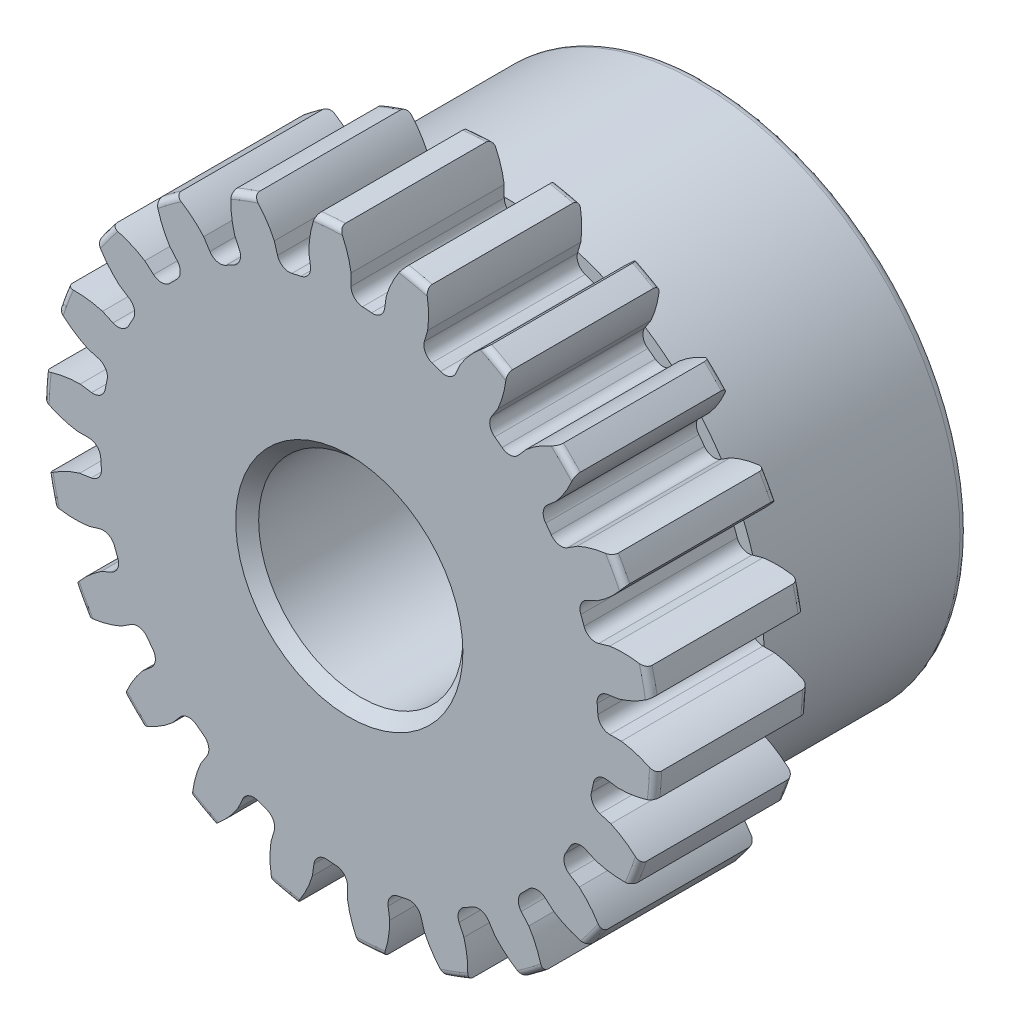
from build123d import *

# Parameters (mm, degrees)
SKETCH1_R                = 9.525
BOSS_EXTRUDE1_DEPTH      = 4.7625
SKETCH2_W                = 6.35
SKETCH2_H                = 7.14375
REVOLVE1_ANGLE           = 360
FILLET2_R                = 0.1905
CUT_EXTRUDE1_DEPTH       = 12.1125
FILLET1_R                = 0.374318784
CIRPATTERN1_COUNT        = 22
FILLET1_OF_CIRPATTERN1_R = 0.374318784
SKETCH5_R                = 3.175
CUT_EXTRUDE2_DEPTH       = 12.1125
CHAMFER1_SIZE            = 0.3571875
SKETCH6_R                = 8.128
BOSS_EXTRUDE2_DEPTH      = 6.35
FILLET3_R                = 0.254


with BuildPart() as part:
    # Sketch1 → Boss-Extrude1 (new body)
    with BuildSketch(Plane.XY):
        Circle(SKETCH1_R)
    extrude(amount=-BOSS_EXTRUDE1_DEPTH)

    # Sketch2 → Revolve1 (revolve, symmetric)
    with BuildSketch(Plane(origin=(0, 0, 0), x_dir=(0, 0, -1), z_dir=(1, 0, 0))) as revolve1_sk:
        with Locations((7.9375, 3.571875)):
            Rectangle(SKETCH2_W, SKETCH2_H)
    revolve(axis=Axis((0, 0, -4.7625), (0, 0, -1)), revolution_arc=REVOLVE1_ANGLE / 2)
    revolve(revolve1_sk.sketch, axis=Axis((0, 0, -4.7625), (0, 0, 1)), revolution_arc=REVOLVE1_ANGLE / 2)

    # Fillet2
    fillet2_edges = [part.edges().sort_by_distance(p)[0] for p in [
        (-9.525, 0, 0),
        (-9.525, 0, -4.7625),
    ]]
    fillet(fillet2_edges, radius=FILLET2_R)

    # Sketch4 → Cut-Extrude1 (cut, through all)
    with BuildSketch(Plane.XY):
        with BuildLine():
            Line((0.054821567, 8.459109181), (0.054821567, 7.73756943))
            ThreePointArc((0.054821567, 7.73756943), (0.552007026, 7.718048609), (1.04690994, 7.666613703))
            Line((1.04690994, 7.666613703), (1.149595991, 8.380809185))
            add(Edge.make_bspline(
                [(2.328590945, 10.036363463), (1.44460819, 9.360987761), (1.149595991, 8.380809185)],
                knots=[0, 0, 0, 1, 1, 1], degree=2))
            ThreePointArc((2.328590945, 10.036363463), (0.735006268, 10.276706337), (-0.876562375, 10.26560109))
            add(Edge.make_bspline(
                [(-0.876562375, 10.26560109), (-0.097693539, 9.471295617), (0.054821567, 8.459109181)],
                knots=[0, 0, 0, 1, 1, 1], degree=2))
        make_face()
    cut_extrude1 = extrude(amount=-CUT_EXTRUDE1_DEPTH, mode=Mode.SUBTRACT)

    # Fillet1
    fillet1_edges = [part.edges().sort_by_distance(p)[0] for p in [
        (1.04690994, 7.666613703, -2.38125),
        (0.054821567, 7.73756943, -2.38125),
    ]]
    fillet(fillet1_edges, radius=FILLET1_R)

    # CirPattern1: Cut-Extrude1 ×22 about axis
    cirpattern1_axis = Axis((0, 0, -4.7625), (0, 0, 1))
    for i in range(1, CIRPATTERN1_COUNT):
        add(cut_extrude1.rotate(cirpattern1_axis, i * 360 / CIRPATTERN1_COUNT), mode=Mode.SUBTRACT)

    # Fillet1 of CirPattern1
    fillet1_of_cirpattern1_edges = [part.edges().sort_by_distance(p)[0] for p in [
        (-1.15543195, 7.651010593, -2.38125),
        (-2.127324311, 7.439588521, -2.38125),
        (-3.264167614, 7.015568108, -2.38125),
        (-4.137127025, 6.538896396, -2.38125),
        (-5.108459831, 5.811766018, -2.38125),
        (-5.811764312, 5.108461772, -2.38125),
        (-6.538895014, 4.137129208, -2.38125),
        (-7.015567018, 3.264169957, -2.38125),
        (-7.439587811, 2.127326795, -2.38125),
        (-7.651010208, 1.155434505, -2.38125),
        (-7.737569449, -0.054818983, -2.38125),
        (-7.666614053, -1.04690738, -2.38125),
        (-7.408699226, -2.232523654, -2.38125),
        (-7.061114422, -3.164435054, -2.38125),
        (-6.479620254, -4.229362535, -2.38125),
        (-5.883565295, -5.02559902, -2.38125),
        (-5.025600985, -5.883563617, -2.38125),
        (-4.229364699, -6.479618842, -2.38125),
        (-3.164437412, -7.061113365, -2.38125),
        (-2.232526128, -7.408698481, -2.38125),
        (-1.04690994, -7.666613703, -2.38125),
        (-0.054821567, -7.73756943, -2.38125),
        (1.15543195, -7.651010593, -2.38125),
        (2.127324311, -7.439588521, -2.38125),
        (3.264167614, -7.015568108, -2.38125),
        (4.137127025, -6.538896396, -2.38125),
        (5.108459831, -5.811766018, -2.38125),
        (5.811764312, -5.108461772, -2.38125),
        (6.538895014, -4.137129208, -2.38125),
        (7.015567018, -3.264169957, -2.38125),
        (7.439587811, -2.127326795, -2.38125),
        (7.651010208, -1.155434505, -2.38125),
        (7.737569449, 0.054818983, -2.38125),
        (7.666614053, 1.04690738, -2.38125),
        (7.408699226, 2.232523654, -2.38125),
        (7.061114422, 3.164435054, -2.38125),
        (6.479620254, 4.229362535, -2.38125),
        (5.883565295, 5.02559902, -2.38125),
        (5.025600985, 5.883563617, -2.38125),
        (4.229364699, 6.479618842, -2.38125),
        (3.164437412, 7.061113365, -2.38125),
        (2.232526128, 7.408698481, -2.38125),
    ]]
    fillet(fillet1_of_cirpattern1_edges, radius=FILLET1_OF_CIRPATTERN1_R)

    # Sketch5 → Cut-Extrude2 (cut, through all)
    with BuildSketch(Plane.XY):
        Circle(SKETCH5_R)
    extrude(amount=-CUT_EXTRUDE2_DEPTH, mode=Mode.SUBTRACT)

    # Chamfer1
    chamfer1_edges = [part.edges().sort_by_distance(p)[0] for p in [
        (0, -7.14375, -11.1125),
        (-3.175, 0, -11.1125),
        (-3.175, 0, 0),
    ]]
    chamfer(chamfer1_edges, length=CHAMFER1_SIZE)

    # Sketch6 → Boss-Extrude2 (add)
    with BuildSketch(Plane(origin=(0, 0, -4.7625), x_dir=(-1, 0, 0), z_dir=(0, 0, -1))):
        Circle(SKETCH6_R)
    extrude(amount=BOSS_EXTRUDE2_DEPTH)

    # Fillet3
    fillet3_edges = [part.edges().sort_by_distance(p)[0] for p in [
        (8.128, 0, -11.1125),
    ]]
    fillet(fillet3_edges, radius=FILLET3_R)


solid = part.part
